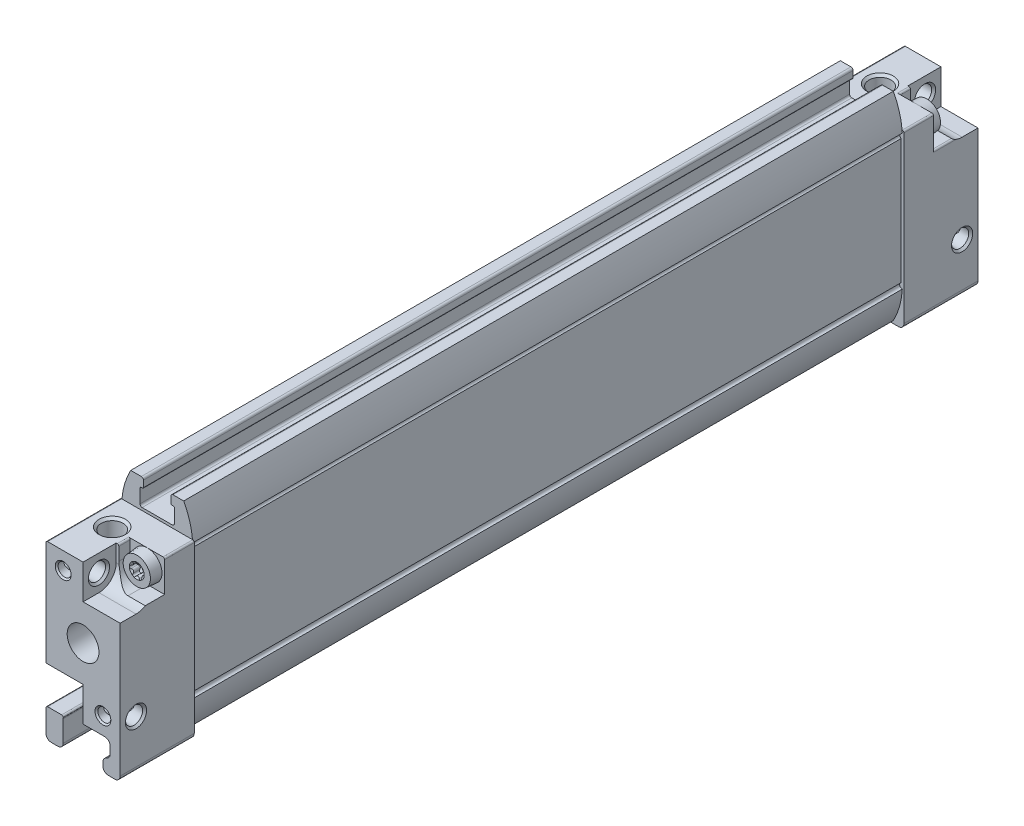
from build123d import *

# Parameters (mm, degrees)
BOSS_EXTRUDE1_DEPTH = 14
BOSS_EXTRUDE2_DEPTH = 134
BOSS_EXTRUDE3_DEPTH = 14
CUT_EXTRUDE1_DEPTH  = 14
CUT_EXTRUDE2_DEPTH  = 14
HOLE1_D             = 2.459
HOLE1_DEPTH         = 5
HOLE1_CSINK_D       = 3
HOLE1_CSINK_ANGLE   = 90
HOLE1_TIP           = 0.709852156
HOLE2_D             = 2.459
HOLE2_DEPTH         = 5
HOLE2_CSINK_D       = 3
HOLE2_CSINK_ANGLE   = 90
HOLE2_TIP           = 0.709852156
HOLE3_D             = 2.459
HOLE3_DEPTH         = 5
HOLE3_CSINK_D       = 3
HOLE3_CSINK_ANGLE   = 90
HOLE3_TIP           = 0.709852156
HOLE4_D             = 2.459
HOLE4_DEPTH         = 5
HOLE4_CSINK_D       = 3
HOLE4_CSINK_ANGLE   = 90
HOLE4_TIP           = 0.709852156
HOLE5_D             = 4
HOLE5_DEPTH         = 7
HOLE6_D             = 2.459
HOLE6_DEPTH         = 6
HOLE6_CSINK_D       = 3
HOLE6_CSINK_ANGLE   = 90
HOLE6_TIP           = 0.709852156
HOLE7_D             = 2.459
HOLE7_DEPTH         = 6
HOLE7_CSINK_D       = 3
HOLE7_CSINK_ANGLE   = 90
HOLE7_TIP           = 0.709852156
HOLE8_D             = 4.134
HOLE8_DEPTH         = 8
HOLE8_CSINK_D       = 5
HOLE8_CSINK_ANGLE   = 90
HOLE8_TIP           = 1.193383006
HOLE9_D             = 4.134
HOLE9_DEPTH         = 7
HOLE9_CSINK_D       = 5
HOLE9_CSINK_ANGLE   = 90
HOLE9_TIP           = 1.193383006
SKETCH27_W          = 30.5
SKETCH27_H          = 3
CUT_EXTRUDE3_DEPTH  = 114.3
CUT_EXTRUDE4_DEPTH  = 14
CUT_EXTRUDE5_DEPTH  = 14
HOLE10_D            = 4.134
HOLE10_DEPTH        = 5
HOLE10_CSINK_D      = 5
HOLE10_CSINK_ANGLE  = 90
HOLE11_D            = 4.134
HOLE11_DEPTH        = 5
HOLE11_CSINK_D      = 5
HOLE11_CSINK_ANGLE  = 90
CUT_EXTRUDE6_DEPTH  = 8.5
CUT_EXTRUDE7_DEPTH  = 8.5
CUT_EXTRUDE8_START  = -8.5
CUT_EXTRUDE8_DEPTH  = 8.5
CUT_EXTRUDE9_START  = -8.5
CUT_EXTRUDE9_DEPTH  = 8.5
CUT_EXTRUDE10_DEPTH = 2.2
CUT_EXTRUDE11_DEPTH = 2.2
CUT_EXTRUDE12_START = 2.2
CUT_EXTRUDE12_DEPTH = 2.2
CUT_EXTRUDE13_START = 2.2
CUT_EXTRUDE13_DEPTH = 2.2


with BuildPart() as part:
    # Sketch1 → Boss-Extrude1 (new body)
    with BuildSketch(Plane.XY):
        with BuildLine():
            Line((-6, -19.25), (-4.75, -19.25))
            ThreePointArc((-4.75, -19.25), (-4.042893219, -18.957106781), (-3.75, -18.25))
            Line((-3.75, -18.25), (-3.75, -14.25))
            ThreePointArc((-3.75, -14.25), (-3.457106781, -13.542893219), (-2.75, -13.25))
            Line((-2.75, -13.25), (4.1, -13.25))
            ThreePointArc((4.1, -13.25), (4.807106781, -13.542893219), (5.1, -14.25))
            Line((5.1, -14.25), (5.1, -15.65))
            ThreePointArc((5.1, -15.65), (4.91394103, -16.230947502), (4.425, -16.595714016))
            ThreePointArc((4.425, -16.595714016), (3.93605897, -16.96048053), (3.75, -17.541428032))
            Line((3.75, -17.541428032), (3.75, -18.25))
            ThreePointArc((3.75, -18.25), (4.042893219, -18.957106781), (4.75, -19.25))
            Line((4.75, -19.25), (6, -19.25))
            ThreePointArc((6, -19.25), (6.707106781, -18.957106781), (7, -18.25))
            Line((7, -18.25), (7, 12.95))
            ThreePointArc((7, 12.95), (6.912132034, 13.162132034), (6.7, 13.25))
            Line((6.7, 13.25), (-6.7, 13.25))
            ThreePointArc((-6.7, 13.25), (-6.912132034, 13.162132034), (-7, 12.95))
            Line((-7, 12.95), (-7, -18.25))
            ThreePointArc((-7, -18.25), (-6.707106781, -18.957106781), (-6, -19.25))
        make_face()
    extrude(amount=-BOSS_EXTRUDE1_DEPTH)

    # Sketch2 → Boss-Extrude2 (add)
    with BuildSketch(Plane.XY.offset(-14)):
        with BuildLine():
            Line((-5, -18.75), (-3, -18.75))
            ThreePointArc((-3, -18.75), (-2.717157288, -18.632842712), (-2.6, -18.35))
            Line((-2.6, -18.35), (-2.6, -17.15))
            ThreePointArc((-2.6, -17.15), (-2.658578644, -17.008578644), (-2.8, -16.95))
            Line((-2.8, -16.95), (-3.05, -16.95))
            ThreePointArc((-3.05, -16.95), (-3.191421356, -16.891421356), (-3.25, -16.75))
            Line((-3.25, -16.75), (-3.25, -14.15))
            ThreePointArc((-3.25, -14.15), (-3.132842712, -13.867157288), (-2.85, -13.75))
            Line((-2.85, -13.75), (2.85, -13.75))
            ThreePointArc((2.85, -13.75), (3.132842712, -13.867157288), (3.25, -14.15))
            Line((3.25, -14.15), (3.25, -16.75))
            ThreePointArc((3.25, -16.75), (3.191421356, -16.891421356), (3.05, -16.95))
            Line((3.05, -16.95), (2.8, -16.95))
            ThreePointArc((2.8, -16.95), (2.658578644, -17.008578644), (2.6, -17.15))
            Line((2.6, -17.15), (2.6, -18.35))
            ThreePointArc((2.6, -18.35), (2.717157288, -18.632842712), (3, -18.75))
            Line((3, -18.75), (5, -18.75))
            ThreePointArc((5, -18.75), (6.188330373, -15.845860272), (6.7, -12.75))
            ThreePointArc((6.7, -12.75), (6.210546844, -12.352154822), (6.5, -11.791742431))
            Line((6.5, -11.791742431), (6.5, 11.791742431))
            ThreePointArc((6.5, 11.791742431), (6.210546844, 12.352154822), (6.7, 12.75))
            ThreePointArc((6.7, 12.75), (6.188330373, 15.845860272), (5, 18.75))
            Line((5, 18.75), (3, 18.75))
            ThreePointArc((3, 18.75), (2.717157288, 18.632842712), (2.6, 18.35))
            Line((2.6, 18.35), (2.6, 17.15))
            ThreePointArc((2.6, 17.15), (2.658578644, 17.008578644), (2.8, 16.95))
            Line((2.8, 16.95), (3.05, 16.95))
            ThreePointArc((3.05, 16.95), (3.191421356, 16.891421356), (3.25, 16.75))
            Line((3.25, 16.75), (3.25, 14.15))
            ThreePointArc((3.25, 14.15), (3.132842712, 13.867157288), (2.85, 13.75))
            Line((2.85, 13.75), (-2.85, 13.75))
            ThreePointArc((-2.85, 13.75), (-3.132842712, 13.867157288), (-3.25, 14.15))
            Line((-3.25, 14.15), (-3.25, 16.75))
            ThreePointArc((-3.25, 16.75), (-3.191421356, 16.891421356), (-3.05, 16.95))
            Line((-3.05, 16.95), (-2.8, 16.95))
            ThreePointArc((-2.8, 16.95), (-2.658578644, 17.008578644), (-2.6, 17.15))
            Line((-2.6, 17.15), (-2.6, 18.35))
            ThreePointArc((-2.6, 18.35), (-2.717157288, 18.632842712), (-3, 18.75))
            Line((-3, 18.75), (-5, 18.75))
            ThreePointArc((-5, 18.75), (-6.188330373, 15.845860272), (-6.7, 12.75))
            ThreePointArc((-6.7, 12.75), (-6.210546844, 12.352154822), (-6.5, 11.791742431))
            Line((-6.5, 11.791742431), (-6.5, -11.791742431))
            ThreePointArc((-6.5, -11.791742431), (-6.210546844, -12.352154822), (-6.7, -12.75))
            ThreePointArc((-6.7, -12.75), (-6.188330373, -15.845860272), (-5, -18.75))
        make_face()
    extrude(amount=-BOSS_EXTRUDE2_DEPTH)

    # Sketch3 → Boss-Extrude3 (add)
    with BuildSketch(Plane.XY.offset(-148)):
        with BuildLine():
            Line((-6, -19.25), (-4.75, -19.25))
            ThreePointArc((-4.75, -19.25), (-4.042893219, -18.957106781), (-3.75, -18.25))
            Line((-3.75, -18.25), (-3.75, -14.25))
            ThreePointArc((-3.75, -14.25), (-3.457106781, -13.542893219), (-2.75, -13.25))
            Line((-2.75, -13.25), (4.1, -13.25))
            ThreePointArc((4.1, -13.25), (4.807106781, -13.542893219), (5.1, -14.25))
            Line((5.1, -14.25), (5.1, -15.65))
            ThreePointArc((5.1, -15.65), (4.91394103, -16.230947502), (4.425, -16.595714016))
            ThreePointArc((4.425, -16.595714016), (3.93605897, -16.96048053), (3.75, -17.541428032))
            Line((3.75, -17.541428032), (3.75, -18.25))
            ThreePointArc((3.75, -18.25), (4.042893219, -18.957106781), (4.75, -19.25))
            Line((4.75, -19.25), (6, -19.25))
            ThreePointArc((6, -19.25), (6.707106781, -18.957106781), (7, -18.25))
            Line((7, -18.25), (7, 12.95))
            ThreePointArc((7, 12.95), (6.912132034, 13.162132034), (6.7, 13.25))
            Line((6.7, 13.25), (-6.7, 13.25))
            ThreePointArc((-6.7, 13.25), (-6.912132034, 13.162132034), (-7, 12.95))
            Line((-7, 12.95), (-7, -18.25))
            ThreePointArc((-7, -18.25), (-6.707106781, -18.957106781), (-6, -19.25))
        make_face()
    extrude(amount=-BOSS_EXTRUDE3_DEPTH)

    # Sketch4 → Cut-Extrude1 (cut)
    with BuildSketch(Plane(origin=(0, 0, 0), x_dir=(0, 0, -1), z_dir=(1, 0, 0))):
        with BuildLine():
            Line((0, 13.25), (0, 6.75))
            Line((0, 6.75), (3, 6.75))
            ThreePointArc((3, 6.75), (5.298097039, 7.701902961), (6.25, 10))
            Line((6.25, 10), (6.25, 13.25))
            Line((6.25, 13.25), (0, 13.25))
        make_face()
    extrude(amount=CUT_EXTRUDE1_DEPTH, mode=Mode.SUBTRACT)

    # Sketch5 → Cut-Extrude2 (cut)
    with BuildSketch(Plane(origin=(0, 0, 0), x_dir=(0, 0, -1), z_dir=(1, 0, 0))):
        with BuildLine():
            Line((159, 6.75), (162, 6.75))
            Line((162, 6.75), (162, 13.25))
            Line((162, 13.25), (155.75, 13.25))
            Line((155.75, 13.25), (155.75, 10))
            ThreePointArc((155.75, 10), (156.701902961, 7.701902961), (159, 6.75))
        make_face()
    extrude(amount=CUT_EXTRUDE2_DEPTH, mode=Mode.SUBTRACT)

    # Sketch6 → Cut-Revolve1 (revolve, cut)
    with BuildSketch(Plane.XY.offset(-3)):
        Polygon((-7, 10), (-7, 12), (-6.621, 11.621), (-0.379, 11.621), (0, 12), (0, 10), align=None)
    revolve(axis=Axis((0, 10, -3), (-1, 0, 0)), mode=Mode.SUBTRACT)

    # Sketch7 → Cut-Revolve2 (revolve, cut)
    with BuildSketch(Plane.XY.offset(-159)):
        Polygon((-7, 10), (-7, 12), (-6.621, 11.621), (-0.379, 11.621), (0, 12), (0, 10), align=None)
    revolve(axis=Axis((0, 10, -159), (-1, 0, 0)), mode=Mode.SUBTRACT)

    # Hole1
    with Locations(Plane.XY):
        with Locations((-3.75, 10)):
            CounterSinkHole(HOLE1_D / 2, HOLE1_CSINK_D / 2, depth=HOLE1_DEPTH, counter_sink_angle=HOLE1_CSINK_ANGLE)
            with Locations((0, 0, -(HOLE1_DEPTH + HOLE1_TIP / 2))):  # 120° drill point
                Cone(0, HOLE1_D / 2, HOLE1_TIP, mode=Mode.SUBTRACT)

    # Hole2
    with Locations(Plane(origin=(0, 0, -162), x_dir=(-1, 0, 0), z_dir=(0, 0, -1))):
        with Locations((3.75, 10)):
            CounterSinkHole(HOLE2_D / 2, HOLE2_CSINK_D / 2, depth=HOLE2_DEPTH, counter_sink_angle=HOLE2_CSINK_ANGLE)
            with Locations((0, 0, -(HOLE2_DEPTH + HOLE2_TIP / 2))):  # 120° drill point
                Cone(0, HOLE2_D / 2, HOLE2_TIP, mode=Mode.SUBTRACT)

    # Hole3
    with Locations(Plane.XY):
        with Locations((3.75, -10)):
            CounterSinkHole(HOLE3_D / 2, HOLE3_CSINK_D / 2, depth=HOLE3_DEPTH, counter_sink_angle=HOLE3_CSINK_ANGLE)
            with Locations((0, 0, -(HOLE3_DEPTH + HOLE3_TIP / 2))):  # 120° drill point
                Cone(0, HOLE3_D / 2, HOLE3_TIP, mode=Mode.SUBTRACT)

    # Hole4
    with Locations(Plane(origin=(0, 0, -162), x_dir=(-1, 0, 0), z_dir=(0, 0, -1))):
        with Locations((-3.75, -10)):
            CounterSinkHole(HOLE4_D / 2, HOLE4_CSINK_D / 2, depth=HOLE4_DEPTH, counter_sink_angle=HOLE4_CSINK_ANGLE)
            with Locations((0, 0, -(HOLE4_DEPTH + HOLE4_TIP / 2))):  # 120° drill point
                Cone(0, HOLE4_D / 2, HOLE4_TIP, mode=Mode.SUBTRACT)

    # Hole5
    with Locations(Plane(origin=(0, 0, -162), x_dir=(-1, 0, 0), z_dir=(0, 0, -1))):
        with Locations((0, 0)):
            Hole(HOLE5_D / 2, depth=HOLE5_DEPTH)

    # Hole6
    with Locations(Plane(origin=(0, -13.25, 0), x_dir=(-1, 0, 0), z_dir=(0, -1, 0))):
        with Locations((0, 11)):
            CounterSinkHole(HOLE6_D / 2, HOLE6_CSINK_D / 2, depth=HOLE6_DEPTH, counter_sink_angle=HOLE6_CSINK_ANGLE)
            with Locations((0, 0, -(HOLE6_DEPTH + HOLE6_TIP / 2))):  # 120° drill point
                Cone(0, HOLE6_D / 2, HOLE6_TIP, mode=Mode.SUBTRACT)

    # Hole7
    with Locations(Plane(origin=(0, -13.25, 0), x_dir=(-1, 0, 0), z_dir=(0, -1, 0))):
        with Locations((0, 151)):
            CounterSinkHole(HOLE7_D / 2, HOLE7_CSINK_D / 2, depth=HOLE7_DEPTH, counter_sink_angle=HOLE7_CSINK_ANGLE)
            with Locations((0, 0, -(HOLE7_DEPTH + HOLE7_TIP / 2))):  # 120° drill point
                Cone(0, HOLE7_D / 2, HOLE7_TIP, mode=Mode.SUBTRACT)

    # Hole8
    with Locations(Plane(origin=(0, 13.25, 0), x_dir=(1, 0, 0), z_dir=(0, 1, 0))):
        with Locations((-3, 8.5)):
            CounterSinkHole(HOLE8_D / 2, HOLE8_CSINK_D / 2, depth=HOLE8_DEPTH, counter_sink_angle=HOLE8_CSINK_ANGLE)
            with Locations((0, 0, -(HOLE8_DEPTH + HOLE8_TIP / 2))):  # 120° drill point
                Cone(0, HOLE8_D / 2, HOLE8_TIP, mode=Mode.SUBTRACT)

    # Hole9
    with Locations(Plane(origin=(0, 13.25, 0), x_dir=(1, 0, 0), z_dir=(0, 1, 0))):
        with Locations((-3, 153.5)):
            CounterSinkHole(HOLE9_D / 2, HOLE9_CSINK_D / 2, depth=HOLE9_DEPTH, counter_sink_angle=HOLE9_CSINK_ANGLE)
            with Locations((0, 0, -(HOLE9_DEPTH + HOLE9_TIP / 2))):  # 120° drill point
                Cone(0, HOLE9_D / 2, HOLE9_TIP, mode=Mode.SUBTRACT)

    # Sketch27 → Cut-Revolve3 (revolve, cut)
    with BuildSketch(Plane(origin=(0, 0, 0), x_dir=(0, 0, -1), z_dir=(1, 0, 0))):
        with Locations((15.25, 1.5)):
            Rectangle(SKETCH27_W, SKETCH27_H)
    revolve(axis=Axis((0, 0, -30.5), (0, 0, 1)), mode=Mode.SUBTRACT)

    # Sketch26 → Cut-Extrude3 (cut)
    with BuildSketch(Plane.XY.offset(-138.15)):
        with BuildLine():
            Line((4.5, -4.5), (4.5, 4.5))
            ThreePointArc((4.5, 4.5), (3.181980515, 7.681980515), (0, 9))
            ThreePointArc((0, 9), (-3.181980515, 7.681980515), (-4.5, 4.5))
            Line((-4.5, 4.5), (-4.5, -4.5))
            ThreePointArc((-4.5, -4.5), (-3.181980515, -7.681980515), (0, -9))
            ThreePointArc((0, -9), (3.181980515, -7.681980515), (4.5, -4.5))
        make_face()
    extrude(amount=CUT_EXTRUDE3_DEPTH, mode=Mode.SUBTRACT)

    # Sketch28 → Cut-Extrude4 (cut)
    with BuildSketch(Plane(origin=(0, 0, 0), x_dir=(0, 0, -1), z_dir=(1, 0, 0))):
        with BuildLine():
            Line((-1, -6.75), (-1, -13.25))
            Line((-1, -13.25), (3, -13.25))
            ThreePointArc((3, -13.25), (6.25, -10), (3, -6.75))
            Line((3, -6.75), (-1, -6.75))
        make_face()
    extrude(amount=-CUT_EXTRUDE4_DEPTH, mode=Mode.SUBTRACT)

    # Sketch29 → Cut-Revolve4 (revolve, cut)
    with BuildSketch(Plane.XY.offset(-3)):
        Polygon((0, -10), (0, -8), (0.379, -8.379), (6.621, -8.379), (7, -8), (7, -10), align=None)
    revolve(axis=Axis((7, -10, -3), (-1, 0, 0)), mode=Mode.SUBTRACT)

    # Sketch30 → Cut-Extrude5 (cut)
    with BuildSketch(Plane(origin=(0, 0, 0), x_dir=(0, 0, -1), z_dir=(1, 0, 0))):
        with BuildLine():
            Line((159, -13.25), (163, -13.25))
            Line((163, -13.25), (163, -6.75))
            Line((163, -6.75), (159, -6.75))
            ThreePointArc((159, -6.75), (155.75, -10), (159, -13.25))
        make_face()
    extrude(amount=-CUT_EXTRUDE5_DEPTH, mode=Mode.SUBTRACT)

    # Sketch31 → Cut-Revolve5 (revolve, cut)
    with BuildSketch(Plane.XY.offset(-159)):
        Polygon((0, -10), (0, -8), (0.379, -8.379), (6.621, -8.379), (7, -8), (7, -10), align=None)
    revolve(axis=Axis((7, -10, -159), (-1, 0, 0)), mode=Mode.SUBTRACT)

    # Hole10
    with Locations(Plane(origin=(0, 0, -162), x_dir=(-1, 0, 0), z_dir=(0, 0, -1))):
        with Locations((-2.5, -4.75)):
            CounterSinkHole(HOLE10_D / 2, HOLE10_CSINK_D / 2, depth=HOLE10_DEPTH, counter_sink_angle=HOLE10_CSINK_ANGLE)

    # Hole11
    with Locations(Plane(origin=(0, 0, -162), x_dir=(-1, 0, 0), z_dir=(0, 0, -1))):
        with Locations((2.5, 4.75)):
            CounterSinkHole(HOLE11_D / 2, HOLE11_CSINK_D / 2, depth=HOLE11_DEPTH, counter_sink_angle=HOLE11_CSINK_ANGLE)

    # Sketch36 → Cut-Extrude6 (cut)
    with BuildSketch(Plane.XY.offset(-8.4)):
        with BuildLine():
            Line((0.5, 12.95), (0.5, 10.5))
            ThreePointArc((0.5, 10.5), (1.451902961, 8.201902961), (3.75, 7.25))
            Line((3.75, 7.25), (7, 7.25))
            Line((7, 7.25), (7, 14.25))
            Line((7, 14.25), (0.2, 14.25))
            Line((0.2, 14.25), (0.2, 13.25))
            ThreePointArc((0.2, 13.25), (0.412132034, 13.162132034), (0.5, 12.95))
        make_face()
    extrude(amount=CUT_EXTRUDE6_DEPTH, mode=Mode.SUBTRACT)

    # Sketch37 → Cut-Extrude7 (cut)
    with BuildSketch(Plane.XY.offset(-8.4)):
        with BuildLine():
            Line((-8, -14.05), (-7, -14.05))
            ThreePointArc((-7, -14.05), (-6.912132034, -13.837867966), (-6.7, -13.75))
            Line((-6.7, -13.75), (-4.05, -13.75))
            ThreePointArc((-4.05, -13.75), (-3.837867966, -13.837867966), (-3.75, -14.05))
            Line((-3.75, -14.05), (-0.090202025, -14.05))
            Line((-0.090202025, -14.05), (-1.397659805, -12.74254222))
            ThreePointArc((-1.397659805, -12.74254222), (-0.762462367, -9.22050053), (-3.75, -7.25))
            Line((-3.75, -7.25), (-8, -7.25))
            Line((-8, -7.25), (-8, -14.05))
        make_face()
    extrude(amount=CUT_EXTRUDE7_DEPTH, mode=Mode.SUBTRACT)

    # Sketch38 → Cut-Extrude8 (cut)
    with BuildSketch(Plane.XY.offset(-153.6).offset(CUT_EXTRUDE8_START)):
        with BuildLine():
            Line((0.5, 12.95), (0.5, 10.5))
            ThreePointArc((0.5, 10.5), (1.451902961, 8.201902961), (3.75, 7.25))
            Line((3.75, 7.25), (6.7, 7.25))
            ThreePointArc((6.7, 7.25), (6.912132034, 7.162132034), (7, 6.95))
            Line((7, 6.95), (8, 6.95))
            Line((8, 6.95), (8, 14.25))
            Line((8, 14.25), (0.2, 14.25))
            Line((0.2, 14.25), (0.2, 13.25))
            ThreePointArc((0.2, 13.25), (0.412132034, 13.162132034), (0.5, 12.95))
        make_face()
    extrude(amount=CUT_EXTRUDE8_DEPTH, mode=Mode.SUBTRACT)

    # Sketch39 → Cut-Extrude9 (cut)
    with BuildSketch(Plane.XY.offset(-153.6).offset(CUT_EXTRUDE9_START)):
        with BuildLine():
            Line((-8, -6.95), (-8, -14.05))
            Line((-8, -14.05), (-7, -14.05))
            ThreePointArc((-7, -14.05), (-6.912132034, -13.837867966), (-6.7, -13.75))
            Line((-6.7, -13.75), (-4.05, -13.75))
            ThreePointArc((-4.05, -13.75), (-3.837867966, -13.837867966), (-3.75, -14.05))
            Line((-3.75, -14.05), (-0.090202025, -14.05))
            Line((-0.090202025, -14.05), (-1.397659805, -12.74254222))
            ThreePointArc((-1.397659805, -12.74254222), (-0.762462367, -9.22050053), (-3.75, -7.25))
            Line((-3.75, -7.25), (-6.7, -7.25))
            ThreePointArc((-6.7, -7.25), (-6.912132034, -7.162132034), (-7, -6.95))
            Line((-7, -6.95), (-8, -6.95))
        make_face()
    extrude(amount=CUT_EXTRUDE9_DEPTH, mode=Mode.SUBTRACT)

    # Sketch40 → Revolve1 (revolve)
    with BuildSketch(Plane(origin=(3.75, 0, 0), x_dir=(0, 0, -1), z_dir=(1, 0, 0))):
        Polygon((7.208290377, 10.5), (6.4, 11.9), (6.4, 13.075022673), (8.4, 13.25), (8.4, 10.5), align=None)
    revolve(axis=Axis((3.75, 10.5, -8.4), (0, 0, 1)))

    # Sketch41 → Revolve2 (revolve)
    with BuildSketch(Plane(origin=(-3.75, 0, 0), x_dir=(0, 0, -1), z_dir=(1, 0, 0))):
        Polygon((7.208290377, -10.5), (6.4, -9.1), (6.4, -7.924977327), (8.4, -7.75), (8.4, -10.5), align=None)
    revolve(axis=Axis((-3.75, -10.5, -8.4), (0, 0, 1)))

    # Sketch42 → Revolve3 (revolve)
    with BuildSketch(Plane(origin=(3.75, 0, 0), x_dir=(0, 0, -1), z_dir=(1, 0, 0))):
        Polygon((153.6, 10.5), (153.6, 13.25), (155.6, 13.075022673), (155.6, 11.9), (154.791709623, 10.5), align=None)
    revolve(axis=Axis((3.75, 10.5, -154.791709623), (0, 0, 1)))

    # Sketch43 → Revolve4 (revolve)
    with BuildSketch(Plane(origin=(-3.75, 0, 0), x_dir=(0, 0, -1), z_dir=(1, 0, 0))):
        Polygon((153.6, -10.5), (153.6, -7.75), (155.6, -7.924977327), (155.6, -9.1), (154.791709623, -10.5), align=None)
    revolve(axis=Axis((-3.75, -10.5, -154.791709623), (0, 0, 1)))

    # Sketch44 → Cut-Extrude10 (cut)
    with BuildSketch(Plane.XY.offset(-6.4)):
        with BuildLine():
            ThreePointArc((2.565387495, 10.772443066), (2.35, 10.49999999), (2.565387514, 10.227556929))
            ThreePointArc((2.565387514, 10.227556929), (2.876668066, 9.995781556), (2.921751129, 9.610317001))
            ThreePointArc((2.921751129, 9.610317001), (3.050000007, 9.287564431), (3.393636369, 9.337873949))
            ThreePointArc((3.393636369, 9.337873949), (3.749999996, 9.491563137), (4.106363626, 9.337873955))
            ThreePointArc((4.106363626, 9.337873955), (4.449999988, 9.287564428), (4.578248872, 9.610316999))
            ThreePointArc((4.578248872, 9.610316999), (4.623331938, 9.995781564), (4.934612505, 10.227556934))
            ThreePointArc((4.934612505, 10.227556934), (5.15, 10.5), (4.934612505, 10.772443066))
            ThreePointArc((4.934612505, 10.772443066), (4.623331946, 11.004218423), (4.578248863, 11.389682972))
            ThreePointArc((4.578248863, 11.389682972), (4.450000008, 11.712435561), (4.106363636, 11.662126056))
            ThreePointArc((4.106363636, 11.662126056), (3.75, 11.508436863), (3.393636364, 11.662126056))
            ThreePointArc((3.393636364, 11.662126056), (3.049999995, 11.712435563), (2.921751134, 11.389682979))
            ThreePointArc((2.921751134, 11.389682979), (2.876668056, 11.004218427), (2.565387495, 10.772443066))
        make_face()
    extrude(amount=-CUT_EXTRUDE10_DEPTH, mode=Mode.SUBTRACT)

    # Sketch45 → Cut-Extrude11 (cut)
    with BuildSketch(Plane.XY.offset(-6.4)):
        with BuildLine():
            ThreePointArc((-4.934612505, -10.227556934), (-5.15, -10.50000001), (-4.934612486, -10.772443071))
            ThreePointArc((-4.934612486, -10.772443071), (-4.623331934, -11.004218444), (-4.578248871, -11.389682999))
            ThreePointArc((-4.578248871, -11.389682999), (-4.449999999, -11.712435566), (-4.106363641, -11.662126061))
            ThreePointArc((-4.106363641, -11.662126061), (-3.750000012, -11.508436863), (-3.393636374, -11.662126045))
            ThreePointArc((-3.393636374, -11.662126045), (-3.050000012, -11.712435572), (-2.921751128, -11.389683001))
            ThreePointArc((-2.921751128, -11.389683001), (-2.876668062, -11.004218436), (-2.565387495, -10.772443066))
            ThreePointArc((-2.565387495, -10.772443066), (-2.35, -10.5), (-2.565387495, -10.227556934))
            ThreePointArc((-2.565387495, -10.227556934), (-2.876668055, -9.995781575), (-2.921751135, -9.610317023))
            ThreePointArc((-2.921751135, -9.610317023), (-3.049999997, -9.287564436), (-3.393636369, -9.337873949))
            ThreePointArc((-3.393636369, -9.337873949), (-3.750000004, -9.491563137), (-4.106363636, -9.337873944))
            ThreePointArc((-4.106363636, -9.337873944), (-4.45, -9.287564435), (-4.578248869, -9.61031701))
            ThreePointArc((-4.578248869, -9.61031701), (-4.623331941, -9.995781569), (-4.934612505, -10.227556934))
        make_face()
    extrude(amount=-CUT_EXTRUDE11_DEPTH, mode=Mode.SUBTRACT)

    # Sketch46 → Cut-Extrude12 (cut)
    with BuildSketch(Plane.XY.offset(-155.6).offset(CUT_EXTRUDE12_START)):
        with BuildLine():
            ThreePointArc((2.565387495, 10.772443066), (2.35, 10.49999999), (2.565387514, 10.227556929))
            ThreePointArc((2.565387514, 10.227556929), (2.876668066, 9.995781556), (2.921751129, 9.610317001))
            ThreePointArc((2.921751129, 9.610317001), (3.050000007, 9.287564431), (3.393636369, 9.337873949))
            ThreePointArc((3.393636369, 9.337873949), (3.749999996, 9.491563137), (4.106363626, 9.337873955))
            ThreePointArc((4.106363626, 9.337873955), (4.449999988, 9.287564428), (4.578248872, 9.610316999))
            ThreePointArc((4.578248872, 9.610316999), (4.623331938, 9.995781564), (4.934612505, 10.227556934))
            ThreePointArc((4.934612505, 10.227556934), (5.15, 10.5), (4.934612505, 10.772443066))
            ThreePointArc((4.934612505, 10.772443066), (4.623331946, 11.004218423), (4.578248863, 11.389682972))
            ThreePointArc((4.578248863, 11.389682972), (4.450000008, 11.712435561), (4.106363636, 11.662126056))
            ThreePointArc((4.106363636, 11.662126056), (3.75, 11.508436863), (3.393636364, 11.662126056))
            ThreePointArc((3.393636364, 11.662126056), (3.049999995, 11.712435563), (2.921751134, 11.389682979))
            ThreePointArc((2.921751134, 11.389682979), (2.876668056, 11.004218427), (2.565387495, 10.772443066))
        make_face()
    extrude(amount=-CUT_EXTRUDE12_DEPTH, mode=Mode.SUBTRACT)

    # Sketch47 → Cut-Extrude13 (cut)
    with BuildSketch(Plane.XY.offset(-155.6).offset(CUT_EXTRUDE13_START)):
        with BuildLine():
            ThreePointArc((-4.934612505, -10.227556934), (-5.15, -10.50000001), (-4.934612486, -10.772443071))
            ThreePointArc((-4.934612486, -10.772443071), (-4.623331934, -11.004218444), (-4.578248871, -11.389682999))
            ThreePointArc((-4.578248871, -11.389682999), (-4.449999999, -11.712435566), (-4.106363641, -11.662126061))
            ThreePointArc((-4.106363641, -11.662126061), (-3.750000012, -11.508436863), (-3.393636374, -11.662126045))
            ThreePointArc((-3.393636374, -11.662126045), (-3.050000012, -11.712435572), (-2.921751128, -11.389683001))
            ThreePointArc((-2.921751128, -11.389683001), (-2.876668062, -11.004218436), (-2.565387495, -10.772443066))
            ThreePointArc((-2.565387495, -10.772443066), (-2.35, -10.5), (-2.565387495, -10.227556934))
            ThreePointArc((-2.565387495, -10.227556934), (-2.876668055, -9.995781575), (-2.921751135, -9.610317023))
            ThreePointArc((-2.921751135, -9.610317023), (-3.049999997, -9.287564436), (-3.393636369, -9.337873949))
            ThreePointArc((-3.393636369, -9.337873949), (-3.750000004, -9.491563137), (-4.106363636, -9.337873944))
            ThreePointArc((-4.106363636, -9.337873944), (-4.45, -9.287564435), (-4.578248869, -9.61031701))
            ThreePointArc((-4.578248869, -9.61031701), (-4.623331941, -9.995781569), (-4.934612505, -10.227556934))
        make_face()
    extrude(amount=-CUT_EXTRUDE13_DEPTH, mode=Mode.SUBTRACT)

    # Sketch48 → Revolve5 (revolve)
    with BuildSketch(Plane(origin=(3.75, 0, 0), x_dir=(0, 0, -1), z_dir=(1, 0, 0))):
        Polygon((8.478290377, 10.5), (7.67, 11.9), (8.6, 11.9), (8.6, 10.5), align=None)
    revolve(axis=Axis((3.75, 10.5, -8.6), (0, 0, 1)))

    # Sketch49 → Revolve6 (revolve)
    with BuildSketch(Plane(origin=(3.75, 0, 0), x_dir=(0, 0, -1), z_dir=(1, 0, 0))):
        Polygon((153.4, 10.5), (153.4, 11.9), (154.33, 11.9), (153.521709623, 10.5), align=None)
    revolve(axis=Axis((3.75, 10.5, -153.521709623), (0, 0, 1)))

    # Sketch50 → Revolve7 (revolve)
    with BuildSketch(Plane(origin=(-3.75, 0, 0), x_dir=(0, 0, -1), z_dir=(1, 0, 0))):
        Polygon((8.478290377, -10.5), (7.67, -9.1), (8.6, -9.1), (8.6, -10.5), align=None)
    revolve(axis=Axis((-3.75, -10.5, -8.6), (0, 0, 1)))

    # Sketch51 → Revolve8 (revolve)
    with BuildSketch(Plane(origin=(-3.75, 0, 0), x_dir=(0, 0, -1), z_dir=(1, 0, 0))):
        Polygon((153.4, -10.5), (153.4, -9.1), (154.33, -9.1), (153.521709623, -10.5), align=None)
    revolve(axis=Axis((-3.75, -10.5, -153.521709623), (0, 0, 1)))


solid = part.part
